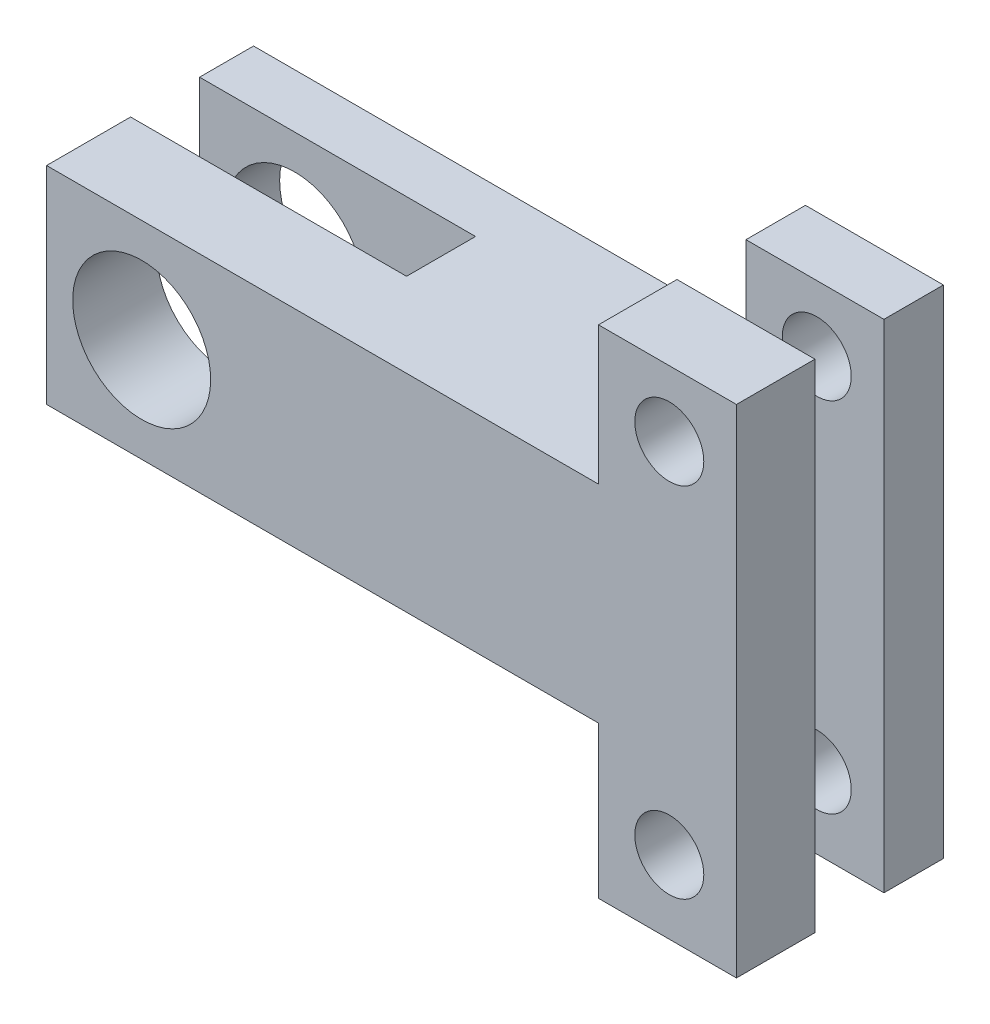
from build123d import *

# Parameters (mm, degrees)
SKETCH1_W           = 50
SKETCH1_H           = 15
BOSS_EXTRUDE1_DEPTH = 15
SKETCH3_W           = 20
SKETCH3_H           = 5
CUT_EXTRUDE1_DEPTH  = 30
SKETCH5_R           = 5
CUT_EXTRUDE2_DEPTH  = 30
SKETCH7_W           = 10
SKETCH7_H           = 15
BOSS_EXTRUDE2_DEPTH = 10
SKETCH11_W          = 10
SKETCH11_H          = 15
BOSS_EXTRUDE5_DEPTH = 11
SKETCH12_R          = 2.5
CUT_EXTRUDE3_DEPTH  = 25
SKETCH13_W          = 5
SKETCH13_H          = 36
CUT_EXTRUDE4_DEPTH  = 10


with BuildPart() as part:
    # Sketch1 → Boss-Extrude1 (new body)
    with BuildSketch(Plane.XY):
        Rectangle(SKETCH1_W, SKETCH1_H)
    extrude(amount=BOSS_EXTRUDE1_DEPTH)

    # Sketch3 → Cut-Extrude1 (cut)
    with BuildSketch(Plane(origin=(0, 7.5, 0), x_dir=(1, 0, 0), z_dir=(0, 1, 0))):
        with Locations((-15, -6.411378574)):
            Rectangle(SKETCH3_W, SKETCH3_H)
    extrude(amount=-CUT_EXTRUDE1_DEPTH, mode=Mode.SUBTRACT)

    # Sketch5 → Cut-Extrude2 (cut)
    with BuildSketch(Plane.XY.offset(15)):
        with Locations((-18.108253402, 0)):
            Circle(SKETCH5_R)
    extrude(amount=-CUT_EXTRUDE2_DEPTH, mode=Mode.SUBTRACT)

    # Sketch7 → Boss-Extrude2 (add)
    with BuildSketch(Plane(origin=(0, 7.5, 0), x_dir=(1, 0, 0), z_dir=(0, 1, 0))):
        with Locations((20, -7.5)):
            Rectangle(SKETCH7_W, SKETCH7_H)
    extrude(amount=BOSS_EXTRUDE2_DEPTH)

    # Sketch11 → Boss-Extrude5 (add)
    with BuildSketch(Plane.XZ.offset(7.5)):
        with Locations((20, 7.5)):
            Rectangle(SKETCH11_W, SKETCH11_H)
    extrude(amount=BOSS_EXTRUDE5_DEPTH)

    # Sketch12 → Cut-Extrude3 (cut)
    with BuildSketch(Plane.XY.offset(15)):
        with Locations((20.132117018, 12.735002854)):
            Circle(SKETCH12_R)
        with Locations((20.132117018, -13.202407166)):
            Circle(SKETCH12_R)
    extrude(amount=-CUT_EXTRUDE3_DEPTH, mode=Mode.SUBTRACT)

    # Sketch13 → Cut-Extrude4 (cut)
    with BuildSketch(Plane(origin=(25, 0, 0), x_dir=(0, 0, -1), z_dir=(1, 0, 0))):
        with Locations((-6.81082534, -0.5)):
            Rectangle(SKETCH13_W, SKETCH13_H)
    extrude(amount=-CUT_EXTRUDE4_DEPTH, mode=Mode.SUBTRACT)


solid = part.part
